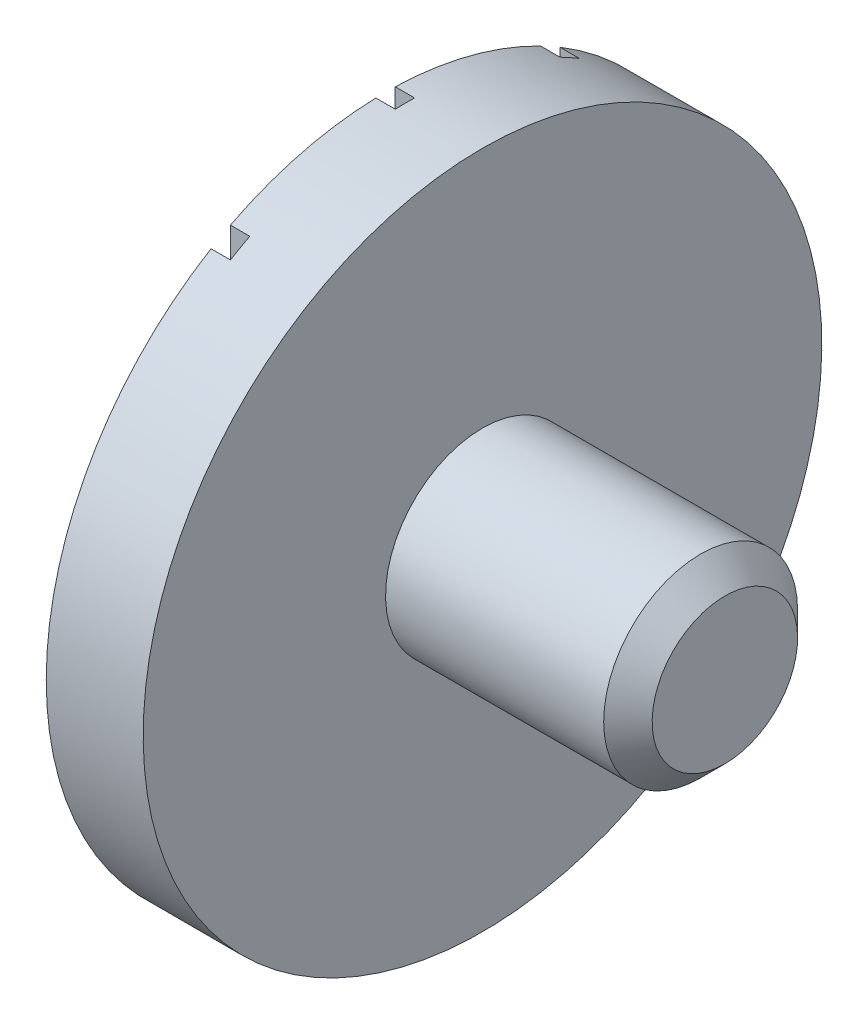
from build123d import *

# Parameters (mm, degrees)
CHAFL_N1_SIZE         = 0.125
CORTAR_EXTRUIR1_DEPTH = 0.1


with BuildPart() as part:
    # Croquis1 → Revolución1 (revolve)
    with BuildSketch(Plane.XY):
        Polygon((0, 0), (0, -1.75), (0.5, -1.75), (0.5, -0.5), (1.75, -0.5), (1.75, 0), align=None)
    revolve(axis=Axis((1.75, 0, 0), (-1, 0, 0)))

    # Chaflán1
    chafl_n1_edges = [part.edges().sort_by_distance(p)[0] for p in [
        (1.75, 0.5, 0),
    ]]
    chamfer(chafl_n1_edges, length=CHAFL_N1_SIZE)

    # Croquis7 → Cortar-Extruir1 (cut)
    with BuildSketch(Plane.ZY):
        with BuildLine():
            Line((-0.05, -1.749285568), (-0.05, 1.749285568))
            ThreePointArc((-0.05, 1.749285568), (0, 1.75), (0.05, 1.749285568))
            Line((0.05, 1.749285568), (0.05, -1.749285568))
            ThreePointArc((0.05, -1.749285568), (0, -1.75), (-0.05, -1.749285568))
        make_face()
        with BuildLine():
            Line((0.8, -1.556438242), (0.8, 1.556438242))
            ThreePointArc((0.8, 1.556438242), (0.850454574, 1.529453176), (0.9, 1.500833102))
            Line((0.9, 1.500833102), (0.9, -1.500833102))
            ThreePointArc((0.9, -1.500833102), (0.850454574, -1.529453176), (0.8, -1.556438242))
        make_face()
        with BuildLine():
            Line((-0.9, -1.500833102), (-0.9, 1.500833102))
            ThreePointArc((-0.9, 1.500833102), (-0.850454574, 1.529453176), (-0.8, 1.556438242))
            Line((-0.8, 1.556438242), (-0.8, -1.556438242))
            ThreePointArc((-0.8, -1.556438242), (-0.850454574, -1.529453176), (-0.9, -1.500833102))
        make_face()
    extrude(amount=-CORTAR_EXTRUIR1_DEPTH, mode=Mode.SUBTRACT)


solid = part.part
